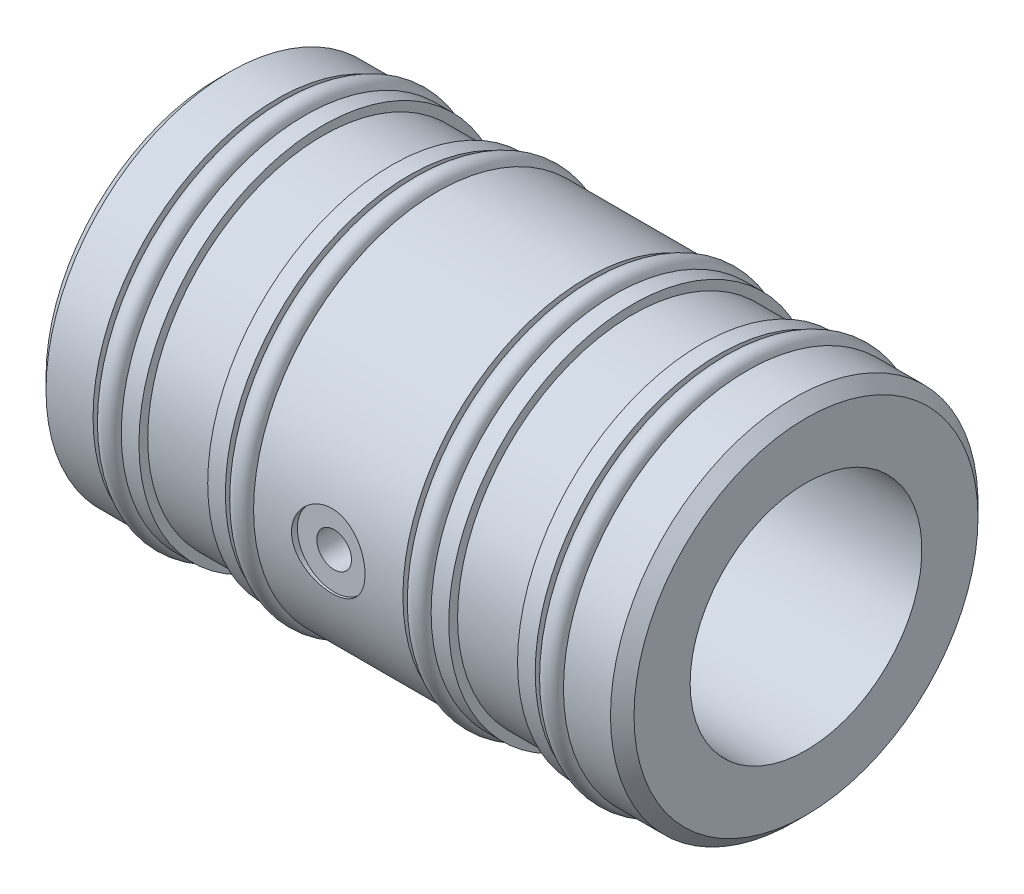
from build123d import *

# Parameters (mm, degrees)
CHAMFER1_SIZE                    = 1.016
F_3_8_0_375_DIAMETER_HOLE1_D     = 6.35
F_3_8_0_375_DIAMETER_HOLE1_DEPTH = 0.508
AIR_HOLE_D                       = 2.4892
AIR_HOLE_DEPTH                   = 6.35
AIR_HOLE_CBORE_D                 = 2.997
AIR_HOLE_CBORE_DEPTH             = 5.994
AIR_HOLE_TIP                     = 0.747831126
SKETCH5_R                        = 0.8763


with BuildPart() as part:
    # Sketch1 → Revolve1 (revolve)
    with BuildSketch(Plane.XY, mode=Mode.PRIVATE) as revolve1_sk:
        Polygon((0, 10.01), (50.8, 10.01), (50.8, 15.875), (45.718, 15.875), (45.718, 14.605), (43.28, 14.605), (43.28, 15.875), (41.754, 15.875), (41.754, 15.113), (35.81, 15.113), (35.81, 15.875), (34.288, 15.875), (34.288, 14.605), (31.85, 14.605), (31.85, 15.875), (18.948, 15.875), (18.948, 14.605), (16.51, 14.605), (16.51, 15.875), (14.986, 15.875), (14.986, 15.113), (9.042, 15.113), (9.042, 15.875), (7.518, 15.875), (7.518, 14.605), (5.08, 14.605), (5.08, 15.875), (0, 15.875), align=None)
    revolve(revolve1_sk.sketch.rotate(Axis((0, 0, 0), (1, 0, 0)), 90), axis=Axis((0, 0, 0), (1, 0, 0)))  # turned: the seam where the file's is

    # Chamfer1
    chamfer1_edges = [part.edges().sort_by_distance(p)[0] for p in [
        (50.8, 0, -15.875),
        (0, 0, -15.875),
    ]]
    chamfer(chamfer1_edges, length=CHAMFER1_SIZE)

    # 3/8 (0.375) Diameter Hole1
    with Locations(Plane(origin=(25.4, 0, 15.875), x_dir=(1, 0, 0), z_dir=(0, 0, 1))):
        with Locations((0, 0)):
            Hole(F_3_8_0_375_DIAMETER_HOLE1_D / 2, depth=F_3_8_0_375_DIAMETER_HOLE1_DEPTH)

    # Air Hole
    with Locations(Plane.XY.offset(15.367)):
        with Locations((25.4, 0)):
            CounterBoreHole(AIR_HOLE_D / 2, AIR_HOLE_CBORE_D / 2, AIR_HOLE_CBORE_DEPTH, depth=AIR_HOLE_DEPTH)
            with Locations((0, 0, -(AIR_HOLE_DEPTH + AIR_HOLE_TIP / 2))):  # 118° drill point
                Cone(0, AIR_HOLE_D / 2, AIR_HOLE_TIP, mode=Mode.SUBTRACT)

    # Sketch5 → Revolve2 (revolve)
    with BuildSketch(Plane.XY, mode=Mode.PRIVATE) as revolve2_sk:
        with Locations((44.5, 15.47876)):
            Circle(SKETCH5_R)
        with Locations((33.07, 15.47876)):
            Circle(SKETCH5_R)
        with Locations((17.728, 15.47876)):
            Circle(SKETCH5_R)
        with Locations((6.2988, 15.47876)):
            Circle(SKETCH5_R)
    revolve(revolve2_sk.sketch.rotate(Axis((0, 0, 0), (1, 0, 0)), 90), axis=Axis((0, 0, 0), (1, 0, 0)))  # turned: the seam where the file's is


solid = part.part
